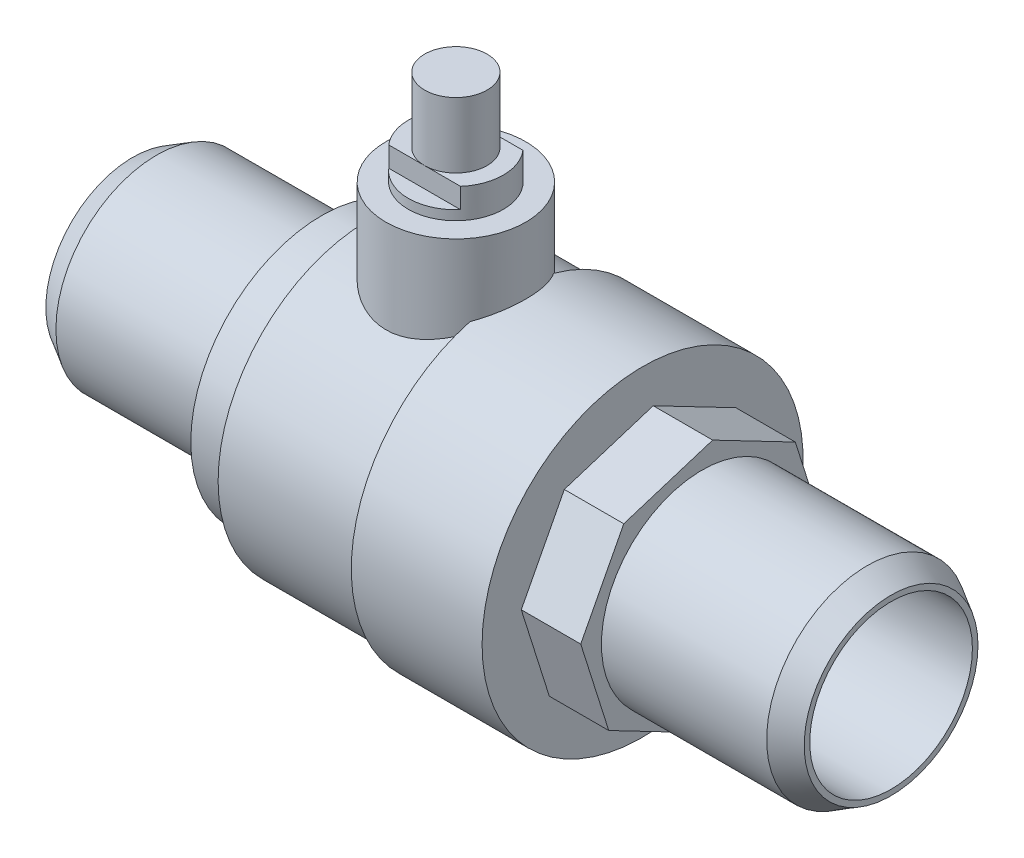
from build123d import *

# Parameters (mm, degrees)
SKETCH1_R               = 8.46455
BOSS_EXTRUDE1_DEPTH     = 31.89
BOSS_EXTRUDE3_DEPTH     = 5
SKETCH6_R               = 13.5
BOSS_EXTRUDE4_DEPTH     = 11
SKETCH7_R               = 12.7
BOSS_EXTRUDE5_DEPTH     = 12
SKETCH8_R               = 11
BOSS_EXTRUDE6_DEPTH     = 4
SKETCH9_R               = 5.875
BOSS_EXTRUDE7_DEPTH     = 19.1
SKETCH10_R              = 4
BOSS_EXTRUDE8_DEPTH     = 2.5
SKETCH11_OUTSIDE_W      = 81.31
SKETCH11_OUTSIDE_H      = 44.53
SKETCH11_OUTSIDE_W_2    = 14.822508056
SKETCH11_OUTSIDE_H_2    = 5.25
CUT_EXTRUDE4_DEPTH      = 1.7
SKETCH12_R              = 2.625
BOSS_EXTRUDE9_DEPTH     = 5.5
SKETCH2_R               = 6.84
CUT_EXTRUDE3_DEPTH      = 32.89
CUT_EXTRUDE3_DEPTH_BACK = 32.89
CHAMFER1_SIZE           = 2
CHAMFER1_SIZE2          = 1.154700538
CHAMFER1_PART_2_SIZE    = 2
CHAMFER1_PART_2_SIZE2   = 1.154700538


with BuildPart() as part:
    # Sketch1 → Boss-Extrude1 (new body, symmetric)
    with BuildSketch(Plane(origin=(0, 0, 0), x_dir=(0, 0, -1), z_dir=(1, 0, 0))):
        Circle(SKETCH1_R)
    extrude(amount=BOSS_EXTRUDE1_DEPTH, both=True)

    # Sketch5 → Boss-Extrude3 (add)
    with BuildSketch(Plane(origin=(15.99, 0, 0), x_dir=(0, 0, -1), z_dir=(1, 0, 0))):
        Polygon((7.845102358, 6.582822495), (0.892566651, 10.202083501), (-6.582822495, 7.845102358), (-10.202083501, 0.892566651), (-7.845102358, -6.582822495), (-0.892566651, -10.202083501), (6.582822495, -7.845102358), (10.202083501, -0.892566651), align=None)
    extrude(amount=-BOSS_EXTRUDE3_DEPTH)

    # Sketch6 → Boss-Extrude4 (add)
    with BuildSketch(Plane.ZY.offset(-10.99)):
        Circle(SKETCH6_R)
    extrude(amount=BOSS_EXTRUDE4_DEPTH)

    # Sketch7 → Boss-Extrude5 (add)
    with BuildSketch(Plane.ZY.offset(0.01)):
        Circle(SKETCH7_R)
    extrude(amount=BOSS_EXTRUDE5_DEPTH)

    # Sketch8 → Boss-Extrude6 (add)
    with BuildSketch(Plane.ZY.offset(12.01)):
        Circle(SKETCH8_R)
    extrude(amount=BOSS_EXTRUDE6_DEPTH)

    # Sketch9 → Boss-Extrude7 (add)
    with BuildSketch(Plane(origin=(0, 0, 0), x_dir=(1, 0, 0), z_dir=(0, 1, 0))):
        with Locations((-4.715, 0)):
            Circle(SKETCH9_R)
    extrude(amount=BOSS_EXTRUDE7_DEPTH)

    # Sketch10 → Boss-Extrude8 (add)
    with BuildSketch(Plane(origin=(0, 19.1, 0), x_dir=(1, 0, 0), z_dir=(0, 1, 0))):
        with Locations((-4.715, 0)):
            Circle(SKETCH10_R)
    extrude(amount=BOSS_EXTRUDE8_DEPTH)

    # Sketch11 outside → Cut-Extrude4 (cut)
    with BuildSketch(Plane(origin=(0, 21.6, 0), x_dir=(1, 0, 0), z_dir=(0, 1, 0))):
        Rectangle(SKETCH11_OUTSIDE_W, SKETCH11_OUTSIDE_H)
        with Locations((-4.715, 0)):
            Rectangle(SKETCH11_OUTSIDE_W_2, SKETCH11_OUTSIDE_H_2, mode=Mode.SUBTRACT)
    extrude(amount=-CUT_EXTRUDE4_DEPTH, mode=Mode.SUBTRACT)

    # Sketch12 → Boss-Extrude9 (add)
    with BuildSketch(Plane(origin=(0, 21.6, 0), x_dir=(1, 0, 0), z_dir=(0, 1, 0))):
        with Locations((-4.715, 0)):
            Circle(SKETCH12_R)
    extrude(amount=BOSS_EXTRUDE9_DEPTH)

    # Sketch2 → Cut-Extrude3 (cut, two sides)
    with BuildSketch(Plane(origin=(0, 0, 0), x_dir=(0, 0, -1), z_dir=(1, 0, 0))) as cut_extrude3_sk:
        Circle(SKETCH2_R)
    extrude(amount=CUT_EXTRUDE3_DEPTH, mode=Mode.SUBTRACT)
    extrude(cut_extrude3_sk.sketch, amount=-CUT_EXTRUDE3_DEPTH_BACK, mode=Mode.SUBTRACT)

    # Chamfer1
    chamfer1_edges = [part.edges().sort_by_distance(p)[0] for p in [
        (-31.89, 0, 8.46455),
    ]]
    chamfer1_side = [part.faces().sort_by_distance(p)[0] for p in [
        (-23.95, 0, 8.46455),
    ]]
    chamfer(chamfer1_edges, length=CHAMFER1_SIZE, length2=CHAMFER1_SIZE2, reference=chamfer1_side[0])

    # Chamfer1 part 2
    chamfer1_part_2_edges = [part.edges().sort_by_distance(p)[0] for p in [
        (31.89, 0, 8.46455),
    ]]
    chamfer1_part_2_side = [part.faces().sort_by_distance(p)[0] for p in [
        (23.94, 0, 8.46455),
    ]]
    chamfer(chamfer1_part_2_edges, length=CHAMFER1_PART_2_SIZE, length2=CHAMFER1_PART_2_SIZE2, reference=chamfer1_part_2_side[0])


solid = part.part
